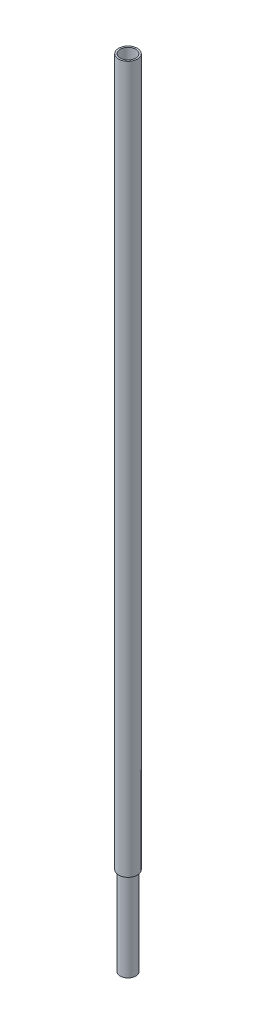
from build123d import *

# Parameters (mm, degrees)
SKETCH_1_R          = 4.25
EXTRUDE_1_DEPTH     = 320
SKETCH_2_R          = 3.5
CUT_EXTRUDE_1_DEPTH = 494
SKETCH_3_R          = 3.5
SKETCH_3_R_2        = 2.5
EXTRUDE_2_DEPTH     = 40


with BuildPart() as part:
    # 草图1 → 凸台-拉伸1 (new body)
    with BuildSketch(Plane(origin=(0, 0, 0), x_dir=(1, 0, 0), z_dir=(0, 1, 0))):
        Circle(SKETCH_1_R)
    extrude(amount=EXTRUDE_1_DEPTH)

    # 草图2 → 切除-拉伸1 (cut)
    with BuildSketch(Plane(origin=(0, 0, 0), x_dir=(1, 0, 0), z_dir=(0, 1, 0))):
        Circle(SKETCH_2_R)
    extrude(amount=CUT_EXTRUDE_1_DEPTH, mode=Mode.SUBTRACT)

    # 草图3 → 凸台-拉伸2 (add, symmetric)
    with BuildSketch(Plane(origin=(0, 0, 0), x_dir=(1, 0, 0), z_dir=(0, 1, 0))):
        Circle(SKETCH_3_R)
        Circle(SKETCH_3_R_2, mode=Mode.SUBTRACT)
    extrude(amount=EXTRUDE_2_DEPTH, both=True)


solid = part.part
